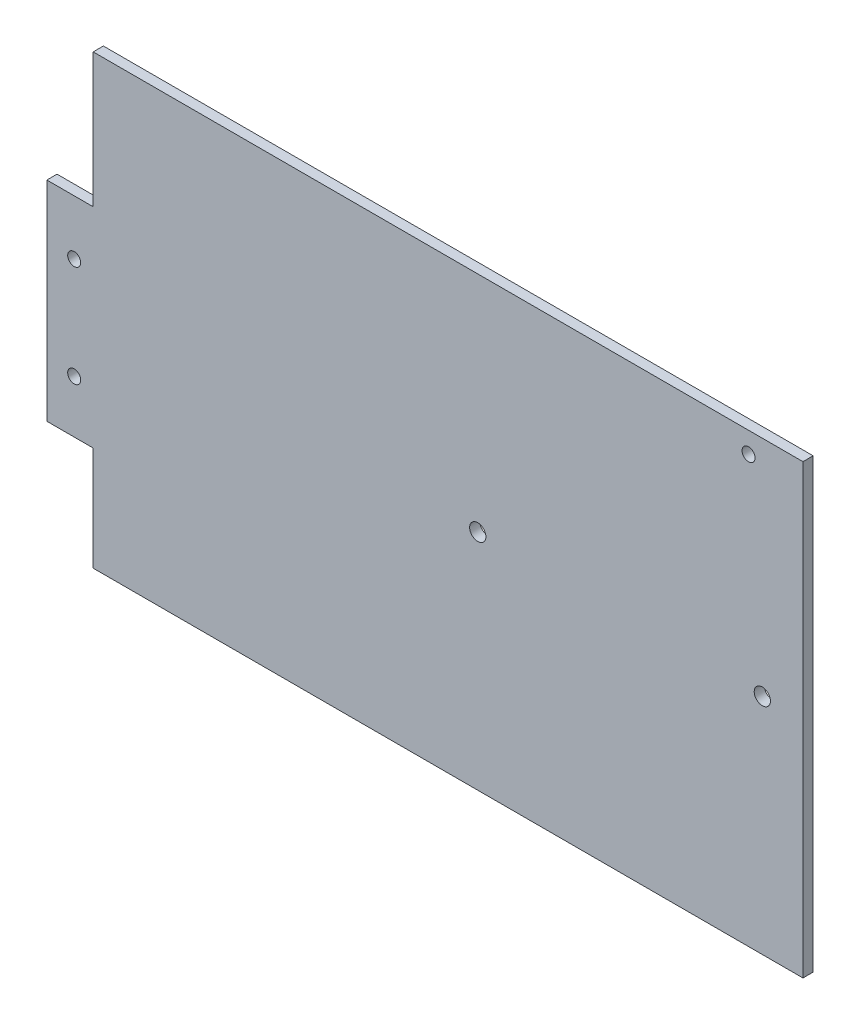
from build123d import *

# Parameters (mm, degrees)
SKETCH1_W           = 221.742
SKETCH1_H           = 139.7
SKETCH1_W_2         = 14.478
SKETCH1_H_2         = 65.278
BOSS_EXTRUDE3_DEPTH = 3.175
SKETCH3_R           = 2.032
CUT_EXTRUDE2_DEPTH  = 4.175
SKETCH4_R           = 2.032
CUT_EXTRUDE3_DEPTH  = 4.175
SKETCH5_R           = 2.54
CUT_EXTRUDE4_DEPTH  = 4.175


with BuildPart() as part:
    # Sketch1 → Boss-Extrude3 (new body)
    with BuildSketch(Plane.XY):
        with Locations((-110.871, 69.85)):
            Rectangle(SKETCH1_W, SKETCH1_H)
        with Locations((-228.981, 65.151)):
            Rectangle(SKETCH1_W_2, SKETCH1_H_2)
    extrude(amount=BOSS_EXTRUDE3_DEPTH)

    # Sketch3 → Cut-Extrude2 (cut, through all)
    with BuildSketch(Plane(origin=(0, 0, 0), x_dir=(-1, 0, 0), z_dir=(0, 0, -1))):
        with Locations((227.680130405, 80.681331583)):
            Circle(SKETCH3_R)
        with Locations((227.680130405, 48.931331583)):
            Circle(SKETCH3_R)
    extrude(amount=-CUT_EXTRUDE2_DEPTH, mode=Mode.SUBTRACT)

    # Sketch4 → Cut-Extrude3 (cut, through all)
    with BuildSketch(Plane.XY.offset(3.175)):
        with Locations((-17, 133.2)):
            Circle(SKETCH4_R)
    extrude(amount=-CUT_EXTRUDE3_DEPTH, mode=Mode.SUBTRACT)

    # Sketch5 → Cut-Extrude4 (cut, through all)
    with BuildSketch(Plane.XY.offset(3.175)):
        with Locations((-101.6, 69.85)):
            Circle(SKETCH5_R)
        with Locations((-12.7, 69.85)):
            Circle(SKETCH5_R)
    extrude(amount=-CUT_EXTRUDE4_DEPTH, mode=Mode.SUBTRACT)


solid = part.part
